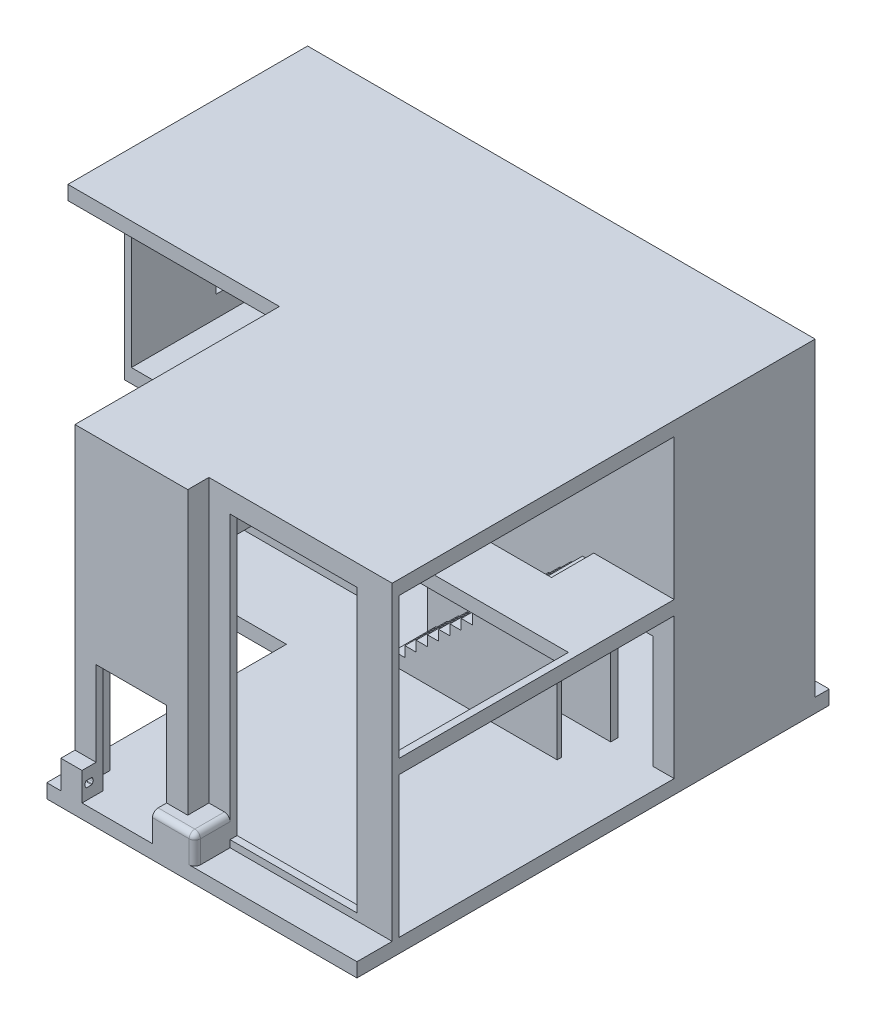
from build123d import *

# Parameters (mm, degrees)
FLOOR_2_DEPTH           = 10
SKETCH6_W               = 25
SKETCH6_H               = 5
FIRST_FLOOR_DEPTH       = 100
SKETCH8_W               = 130
SKETCH8_H               = 45
FLOOR_EXTENSION_DEPTH   = 10
SKETCH7_W               = 340
SKETCH7_H               = 170
SKETCH7_W_2             = 120
SKETCH7_H_2             = 30
CEILING_DEPTH           = 10
SKETCH9_W               = 5
SKETCH9_H               = 60
SKETCH9_W_2             = 25
SKETCH9_H_2             = 5
SECOND_FLOOR_DEPTH      = 100
CEILING_EXTENSION_DEPTH = 10
ROOF_DEPTH              = 10
SKETCH12_W              = 30
SKETCH12_H              = 5
SKETCH12_W_2            = 50
DOORS_FIRST_FLOOR_DEPTH = 20
SKETCH15_W              = 130
SKETCH15_H              = 20
CUT_EXTRUDE1_DEPTH      = 10
SKETCH16_W              = 8
SKETCH16_H              = 3
SKETCH16_W_2            = 4.023664818
BOSS_EXTRUDE1_DEPTH     = 30
BOSS_EXTRUDE4_START     = -5
SKETCH19_W              = 115
SKETCH19_H              = 15
SKETCH19_W_2            = 125
BOSS_EXTRUDE4_DEPTH     = 5
BOSS_EXTRUDE7_START     = -5
SKETCH21_W              = 85
SKETCH21_H              = 15
BOSS_EXTRUDE7_DEPTH     = 5
BOSS_EXTRUDE9_START     = -5
SKETCH22_W              = 40
SKETCH22_H              = 5
BOSS_EXTRUDE9_DEPTH     = 5
BOSS_EXTRUDE10_START    = -5
SKETCH23_W              = 90
SKETCH23_H              = 5
BOSS_EXTRUDE10_DEPTH    = 5
SKETCH24_W              = 130
SKETCH24_H              = 2.5
BOSS_EXTRUDE11_DEPTH    = 35
SKETCH25_W              = 10
SKETCH25_H              = 335
CUT_EXTRUDE2_DEPTH      = 10
SKETCH26_R              = 6
SKETCH26_W              = 15
SKETCH26_H              = 25
CUT_EXTRUDE3_DEPTH      = 5
BOSS_EXTRUDE12_START    = -3
BOSS_EXTRUDE12_DEPTH    = 3
SKETCH28_W              = 15
SKETCH28_H              = 10
BOSS_EXTRUDE13_DEPTH    = 20
SKETCH29_R              = 4.5
CUT_EXTRUDE4_DEPTH      = 20
FILLET2_R               = 4
CUT_EXTRUDE5_DEPTH      = 10


with BuildPart() as part:
    # Sketch5 → Floor 2 (new body)
    with BuildSketch(Plane(origin=(0, 0, 0), x_dir=(1, 0, 0), z_dir=(0, 1, 0))):
        Polygon((-180, 47.5), (-50, 47.5), (-50, -167.5), (180, -167.5), (180, 167.5), (-180, 167.5), align=None)
    extrude(amount=FLOOR_2_DEPTH)

    # Sketch6 → First Floor (add)
    with BuildSketch(Plane(origin=(0, 10, 0), x_dir=(1, 0, 0), z_dir=(0, 1, 0))):
        Polygon((-170, 52.5), (-170, 157.5), (-130, 157.5), (-130, 152.5), (-165, 152.5), (-165, 62.5), (-35, 62.5), (-35, 57.5), (-165, 57.5), (-165, 52.5), align=None)
        Polygon((-15, 157.5), (30, 157.5), (30, 152.5), (10, 152.5), (10, 62.5), (125, 62.5), (125, 57.5), (-5, 57.5), (-5, 62.5), (5, 62.5), (5, 152.5), (-15, 152.5), align=None)
        Polygon((145, 157.5), (170, 157.5), (170, 57.5), (155, 57.5), (155, 62.5), (165, 62.5), (165, 152.5), (145, 152.5), align=None)
        Polygon((-40, -137.5), (-40, -157.5), (-25, -157.5), (-25, -152.5), (-35, -152.5), (-35, -137.5), align=None)
        Polygon((25, -152.5), (25, -157.5), (40, -157.5), (40, -142.5), (55, -142.5), (55, -137.5), (35, -137.5), (35, -152.5), align=None)
        with Locations((157.5, -140)):
            Rectangle(SKETCH6_W, SKETCH6_H)
    extrude(amount=FIRST_FLOOR_DEPTH)

    # Sketch8 → floor extension (add)
    with BuildSketch(Plane(origin=(0, 0, 0), x_dir=(1, 0, 0), z_dir=(0, 1, 0))):
        with Locations((-115, 25)):
            Rectangle(SKETCH8_W, SKETCH8_H)
    extrude(amount=FLOOR_EXTENSION_DEPTH)

    # Sketch7 → ceiling (add)
    with BuildSketch(Plane(origin=(0, 110, 0), x_dir=(1, 0, 0), z_dir=(0, 1, 0))):
        with Locations((0, 72.5)):
            Rectangle(SKETCH7_W, SKETCH7_H)
        with Locations((57, 42.5)):
            Rectangle(SKETCH7_W_2, SKETCH7_H_2, mode=Mode.SUBTRACT)
    extrude(amount=CEILING_DEPTH)

    # Sketch9 → Second floor (add)
    with BuildSketch(Plane(origin=(0, 120, 0), x_dir=(1, 0, 0), z_dir=(0, 1, 0))):
        Polygon((170, 57.5), (170, 157.5), (165, 157.5), (165, 62.5), (35, 62.5), (35, 72.5), (30, 72.5), (30, 57.5), align=None)
        Polygon((-45, 157.5), (35, 157.5), (35, 142.5), (30, 142.5), (30, 152.5), (-45, 152.5), align=None)
        with Locations((-167.5, 37.5)):
            Rectangle(SKETCH9_W, SKETCH9_H)
        Polygon((-40, -157.5), (40, -157.5), (40, -142.5), (55, -142.5), (55, -137.5), (35, -137.5), (35, -152.5), (-40, -152.5), align=None)
        with Locations((157.5, -140)):
            Rectangle(SKETCH9_W_2, SKETCH9_H_2)
    extrude(amount=SECOND_FLOOR_DEPTH)

    # Sketch10 → ceiling extension (add)
    with BuildSketch(Plane(origin=(0, 110, 0), x_dir=(1, 0, 0), z_dir=(0, 1, 0))):
        Polygon((170, -12.5), (165, -12.5), (165, -137.5), (145, -137.5), (145, -142.5), (170, -142.5), align=None)
        Polygon((-35, -152.5), (-35, -12.5), (-40, -12.5), (-40, -157.5), (40, -157.5), (40, -142.5), (55, -142.5), (55, -137.5), (35, -137.5), (35, -152.5), align=None)
    extrude(amount=CEILING_EXTENSION_DEPTH)

    # Sketch11 → Roof (add)
    with BuildSketch(Plane(origin=(0, 220, 0), x_dir=(1, 0, 0), z_dir=(0, 1, 0))):
        Polygon((170, 157.5), (170, -142.5), (40, -142.5), (40, -157.5), (-40, -157.5), (-40, -12.5), (-190, -12.5), (-190, 157.5), align=None)
    extrude(amount=ROOF_DEPTH)

    # Sketch12 → Doors first floor (add)
    with BuildSketch(Plane.XZ.offset(-110)):
        with Locations((-20, -60)):
            Rectangle(SKETCH12_W, SKETCH12_H)
        with Locations((140, -60)):
            Rectangle(SKETCH12_W, SKETCH12_H)
        with Locations((0, 155)):
            Rectangle(SKETCH12_W_2, SKETCH12_H)
    extrude(amount=DOORS_FIRST_FLOOR_DEPTH)

    # Sketch15 → Cut-Extrude1 (cut)
    with BuildSketch(Plane(origin=(0, 110, 0), x_dir=(1, 0, 0), z_dir=(0, 1, 0))):
        with Locations((-105, -2.5)):
            Rectangle(SKETCH15_W, SKETCH15_H)
    extrude(amount=CUT_EXTRUDE1_DEPTH, mode=Mode.SUBTRACT)

    # Sketch16 → Boss-Extrude1 (add)
    with BuildSketch(Plane.XY.offset(-57.5)):
        with Locations((12.998179629, 24.664883143)):
            Rectangle(SKETCH16_W, SKETCH16_H)
        with Locations((5, 17.333333333)):
            Rectangle(SKETCH16_W, SKETCH16_H)
        with Locations((20.996359259, 31.996432953)):
            Rectangle(SKETCH16_W, SKETCH16_H)
        with Locations((28.994538888, 39.327982763)):
            Rectangle(SKETCH16_W, SKETCH16_H)
        with Locations((36.992718518, 46.659532573)):
            Rectangle(SKETCH16_W, SKETCH16_H)
        with Locations((44.990898147, 53.991082383)):
            Rectangle(SKETCH16_W, SKETCH16_H)
        with Locations((52.989077776, 61.322632193)):
            Rectangle(SKETCH16_W, SKETCH16_H)
        with Locations((60.987257406, 68.654182003)):
            Rectangle(SKETCH16_W, SKETCH16_H)
        with Locations((68.985437035, 75.985731813)):
            Rectangle(SKETCH16_W, SKETCH16_H)
        with Locations((76.983616664, 83.317281623)):
            Rectangle(SKETCH16_W, SKETCH16_H)
        with Locations((84.981796294, 90.648831433)):
            Rectangle(SKETCH16_W, SKETCH16_H)
        with Locations((92.979975923, 97.980381243)):
            Rectangle(SKETCH16_W, SKETCH16_H)
        with Locations((100.978155553, 105.311931053)):
            Rectangle(SKETCH16_W, SKETCH16_H)
        with Locations((108.976335182, 112.643480863)):
            Rectangle(SKETCH16_W, SKETCH16_H)
        with Locations((114.988167591, 118.5)):
            Rectangle(SKETCH16_W_2, SKETCH16_H)
    extrude(amount=BOSS_EXTRUDE1_DEPTH)

    # Sketch19 → Boss-Extrude4 (add)
    with BuildSketch(Plane(origin=(0, 0, -157.5), x_dir=(-1, 0, 0), z_dir=(0, 0, -1)).offset(BOSS_EXTRUDE4_START)):
        with Locations((-87.5, 17.5)):
            Rectangle(SKETCH19_W, SKETCH19_H)
        with Locations((-87.5, 102.5)):
            Rectangle(SKETCH19_W, SKETCH19_H)
        with Locations((72.5, 102.5)):
            Rectangle(SKETCH19_W, SKETCH19_H)
        with Locations((72.5, 17.5)):
            Rectangle(SKETCH19_W, SKETCH19_H)
        with Locations((107.5, 127.5)):
            Rectangle(SKETCH19_W_2, SKETCH19_H)
        with Locations((107.5, 212.5)):
            Rectangle(SKETCH19_W_2, SKETCH19_H)
    extrude(amount=BOSS_EXTRUDE4_DEPTH)

    # Sketch21 → Boss-Extrude7 (add)
    with BuildSketch(Plane.ZY.offset(170).offset(BOSS_EXTRUDE7_START)):
        with Locations((-110, 127.5)):
            Rectangle(SKETCH21_W, SKETCH21_H)
        with Locations((-110, 212.5)):
            Rectangle(SKETCH21_W, SKETCH21_H)
    extrude(amount=BOSS_EXTRUDE7_DEPTH)

    # Sketch22 → Boss-Extrude9 (add)
    with BuildSketch(Plane.ZY.offset(170).offset(BOSS_EXTRUDE9_START)):
        with Locations((-32.5, 12.5)):
            Rectangle(SKETCH22_W, SKETCH22_H)
        with Locations((-32.5, 107.5)):
            Rectangle(SKETCH22_W, SKETCH22_H)
    extrude(amount=BOSS_EXTRUDE9_DEPTH)

    # Sketch23 → Boss-Extrude10 (add)
    with BuildSketch(Plane.XY.offset(142.5).offset(BOSS_EXTRUDE10_START)):
        with Locations((100, 12.5)):
            Rectangle(SKETCH23_W, SKETCH23_H)
        with Locations((100, 217.5)):
            Rectangle(SKETCH23_W, SKETCH23_H)
    extrude(amount=BOSS_EXTRUDE10_DEPTH)

    # Sketch24 → Boss-Extrude11 (add)
    with BuildSketch(Plane(origin=(0, 120, 0), x_dir=(1, 0, 0), z_dir=(0, 1, 0))):
        with Locations((100, 155)):
            Rectangle(SKETCH24_W, SKETCH24_H)
    extrude(amount=BOSS_EXTRUDE11_DEPTH)

    # Sketch25 → Cut-Extrude2 (cut)
    with BuildSketch(Plane(origin=(0, 10, 0), x_dir=(1, 0, 0), z_dir=(0, 1, 0))):
        with Locations((175, 0)):
            Rectangle(SKETCH25_W, SKETCH25_H)
    extrude(amount=-CUT_EXTRUDE2_DEPTH, mode=Mode.SUBTRACT)

    # Sketch26 → Cut-Extrude3 (cut)
    with BuildSketch(Plane.XY.offset(-57.5)):
        with Locations((109.690735941, 191.224873497)):
            Circle(SKETCH26_R)
        with Locations((109.690735941, 79.072452826)):
            Rectangle(SKETCH26_W, SKETCH26_H)
    extrude(amount=-CUT_EXTRUDE3_DEPTH, mode=Mode.SUBTRACT)

    # Sketch27 → Boss-Extrude12 (add)
    with BuildSketch(Plane.XY.offset(-27.5).offset(BOSS_EXTRUDE12_START)):
        Polygon((1, 10), (1, 15.833333333), (9, 15.833333333), (8.998179629, 23.164883143), (16.998179629, 23.164883143), (16.996359259, 30.496432953), (24.996359259, 30.496432953), (24.996359259, 37.862653622), (32.994538888, 37.827982763), (32.992718518, 45.159532573), (40.992718518, 45.159532573), (40.990898147, 52.491082383), (48.990898147, 52.491082383), (48.989077776, 59.822632193), (56.989077776, 59.822632193), (56.987257406, 67.154182003), (64.987257406, 67.154182003), (64.985437035, 74.485731813), (72.985437035, 74.485731813), (72.983616664, 81.817281623), (80.983616664, 81.817281623), (80.981796294, 89.148831433), (88.981796294, 89.148831433), (88.979975923, 96.480381243), (96.979975923, 96.480381243), (96.978155553, 103.811931053), (104.978155553, 103.811931053), (104.976335182, 111.143480863), (112.976335182, 111.143480863), (112.976335182, 117), (117, 117), (117, 10), align=None)
    extrude(amount=BOSS_EXTRUDE12_DEPTH)

    # Sketch28 → Boss-Extrude13 (add)
    with BuildSketch(Plane(origin=(0, 10, 0), x_dir=(1, 0, 0), z_dir=(0, 1, 0))):
        Polygon((25, -157.5), (25, -167.5), (55, -167.5), (55, -142.5), (40, -142.5), (40, -157.5), align=None)
        with Locations((-32.5, -162.5)):
            Rectangle(SKETCH28_W, SKETCH28_H)
    extrude(amount=BOSS_EXTRUDE13_DEPTH)

    # Sketch29 → Cut-Extrude4 (cut)
    with BuildSketch(Plane.ZY.offset(-25)):
        with Locations((162.5, 20)):
            Circle(SKETCH29_R)
    extrude(amount=-CUT_EXTRUDE4_DEPTH, mode=Mode.SUBTRACT)

    # Fillet2
    fillet2_edges = [part.edges().sort_by_distance(p)[0] for p in [
        (55, 20, 167.5),
        (40, 30, 167.5),
        (55, 30, 155),
    ]]
    fillet(fillet2_edges, radius=FILLET2_R)

    # Sketch30 → Cut-Extrude5 (cut)
    with BuildSketch(Plane(origin=(-25, 0, 0), x_dir=(0, 0, -1), z_dir=(1, 0, 0))):
        with BuildLine():
            Line((-165.313617374, 20.842378191), (-164.825671533, 21.940122361))
            ThreePointArc((-164.825671533, 21.940122361), (-164.641222233, 22.156284722), (-164.368774957, 22.237032433))
            Line((-164.368774957, 22.237032433), (-160.631225043, 22.237032433))
            ThreePointArc((-160.631225043, 22.237032433), (-160.358777767, 22.156284722), (-160.174328467, 21.940122361))
            Line((-160.174328467, 21.940122361), (-159.686382626, 20.842378191))
            ThreePointArc((-159.686382626, 20.842378191), (-159.507597865, 20), (-159.686382626, 19.157621809))
            Line((-159.686382626, 19.157621809), (-160.174328467, 18.059877639))
            ThreePointArc((-160.174328467, 18.059877639), (-160.358777767, 17.843715278), (-160.631225043, 17.762967567))
            Line((-160.631225043, 17.762967567), (-164.368774957, 17.762967567))
            ThreePointArc((-164.368774957, 17.762967567), (-164.641222233, 17.843715278), (-164.825671533, 18.059877639))
            Line((-164.825671533, 18.059877639), (-165.313617374, 19.157621809))
            ThreePointArc((-165.313617374, 19.157621809), (-165.492402135, 20), (-165.313617374, 20.842378191))
        make_face()
    extrude(amount=-CUT_EXTRUDE5_DEPTH, mode=Mode.SUBTRACT)


solid = part.part
